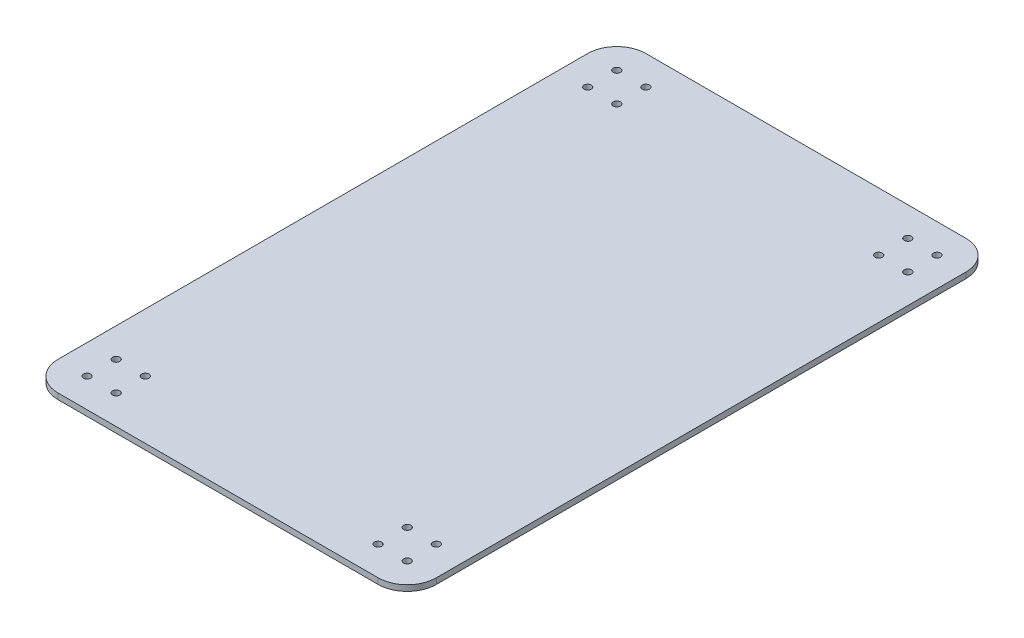
from build123d import *

# Parameters (mm, degrees)
SKETCH1_R           = 3.175
BOSS_EXTRUDE1_DEPTH = 5.08


with BuildPart() as part:
    # Sketch1 → Boss-Extrude1 (new body)
    with BuildSketch(Plane(origin=(0, 0, 0), x_dir=(1, 0, 0), z_dir=(0, 1, 0))):
        with BuildLine():
            Line((-147.260105464, 231.337081644), (132.139894536, 231.337081644))
            ThreePointArc((132.139894536, 231.337081644), (150.100406779, 223.897593887), (157.539894536, 205.937081644))
            Line((157.539894536, 205.937081644), (157.539894536, -256.342918356))
            ThreePointArc((157.539894536, -256.342918356), (150.100406779, -274.303430598), (132.139894536, -281.742918356))
            Line((132.139894536, -281.742918356), (-147.260105464, -281.742918356))
            ThreePointArc((-147.260105464, -281.742918356), (-165.220617706, -274.303430598), (-172.660105464, -256.342918356))
            Line((-172.660105464, -256.342918356), (-172.660105464, 205.937081644))
            ThreePointArc((-172.660105464, 205.937081644), (-165.220617706, 223.897593887), (-147.260105464, 231.337081644))
        make_face()
        with Locations((-147.260105464, 205.937081644)):
            Circle(SKETCH1_R, mode=Mode.SUBTRACT)
        with Locations((-121.860105464, 205.937081644)):
            Circle(SKETCH1_R, mode=Mode.SUBTRACT)
        with Locations((-121.860105464, 180.537081644)):
            Circle(SKETCH1_R, mode=Mode.SUBTRACT)
        with Locations((-147.260105464, 180.537081644)):
            Circle(SKETCH1_R, mode=Mode.SUBTRACT)
        with Locations((132.139894536, 180.537081644)):
            Circle(SKETCH1_R, mode=Mode.SUBTRACT)
        with Locations((106.739894536, 180.537081644)):
            Circle(SKETCH1_R, mode=Mode.SUBTRACT)
        with Locations((106.739894536, 205.937081644)):
            Circle(SKETCH1_R, mode=Mode.SUBTRACT)
        with Locations((132.139894536, 205.937081644)):
            Circle(SKETCH1_R, mode=Mode.SUBTRACT)
        with Locations((132.139894536, -256.342918356)):
            Circle(SKETCH1_R, mode=Mode.SUBTRACT)
        with Locations((106.739894536, -256.342918356)):
            Circle(SKETCH1_R, mode=Mode.SUBTRACT)
        with Locations((106.739894536, -230.942918356)):
            Circle(SKETCH1_R, mode=Mode.SUBTRACT)
        with Locations((132.139894536, -230.942918356)):
            Circle(SKETCH1_R, mode=Mode.SUBTRACT)
        with Locations((-121.860105464, -256.342918356)):
            Circle(SKETCH1_R, mode=Mode.SUBTRACT)
        with Locations((-147.260105464, -256.342918356)):
            Circle(SKETCH1_R, mode=Mode.SUBTRACT)
        with Locations((-147.260105464, -230.942918356)):
            Circle(SKETCH1_R, mode=Mode.SUBTRACT)
        with Locations((-121.860105464, -230.942918356)):
            Circle(SKETCH1_R, mode=Mode.SUBTRACT)
    extrude(amount=BOSS_EXTRUDE1_DEPTH)


solid = part.part
